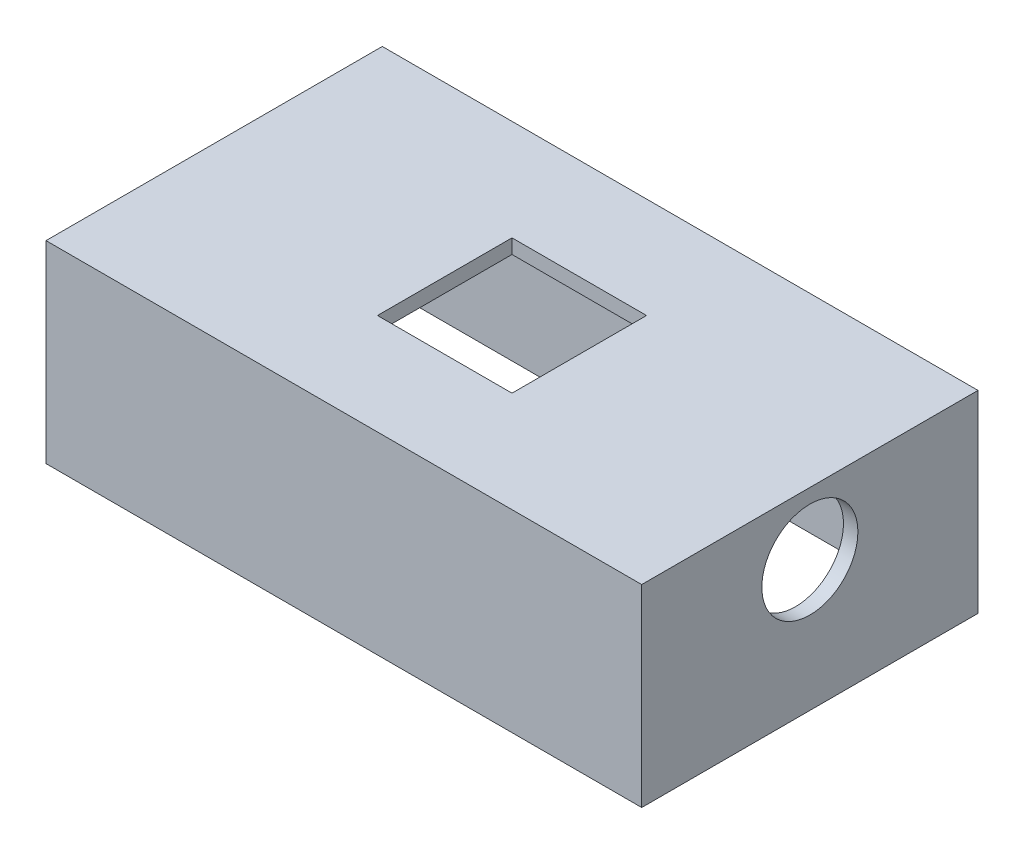
from build123d import *

# Parameters (mm, degrees)
SKETCH_1_W          = 62
SKETCH_1_H          = 35
EXTRUDE_1_DEPTH     = 1.5
SKETCH_2_W          = 62
SKETCH_2_H          = 35
EXTRUDE_2_DEPTH     = 16.1
SKETCH_3_W          = 59
SKETCH_3_H          = 32
CUT_EXTRUDE_1_DEPTH = 41
SKETCH_4_W          = 62
SKETCH_4_H          = 35
SKETCH_4_W_2        = 59
SKETCH_4_H_2        = 32
EXTRUDE_3_DEPTH     = 1
SKETCH_5_W          = 62
SKETCH_5_H          = 35
EXTRUDE_4_DEPTH     = 1.5
SKETCH_8_R          = 5
CUT_EXTRUDE_3_DEPTH = 1.5
CUT_EXTRUDE_4_REACH = 22.1
SKETCH_10_W         = 14
SKETCH_10_H         = 14


with BuildPart() as part:
    # 草图1 → 凸台-拉伸1 (new body)
    with BuildSketch(Plane(origin=(0, 0, 0), x_dir=(1, 0, 0), z_dir=(0, 1, 0))):
        with Locations((2.996831225, 4.751847291)):
            Rectangle(SKETCH_1_W, SKETCH_1_H)
    extrude(amount=EXTRUDE_1_DEPTH)

    # 草图2 → 凸台-拉伸2 (add)
    with BuildSketch(Plane.XZ):
        with Locations((2.996831225, -4.751847291)):
            Rectangle(SKETCH_2_W, SKETCH_2_H)
    extrude(amount=EXTRUDE_2_DEPTH)

    # 草图3 → 切除-拉伸1 (cut)
    with BuildSketch(Plane.XZ.offset(16.1)):
        with Locations((2.996831225, -4.751847291)):
            Rectangle(SKETCH_3_W, SKETCH_3_H)
    extrude(amount=-CUT_EXTRUDE_1_DEPTH, mode=Mode.SUBTRACT)

    # 草图4 → 凸台-拉伸3 (add)
    with BuildSketch(Plane(origin=(0, 1.5, 0), x_dir=(1, 0, 0), z_dir=(0, 1, 0))):
        with Locations((2.996831225, 4.751847291)):
            Rectangle(SKETCH_4_W, SKETCH_4_H)
        with Locations((2.996831225, 4.751847291)):
            Rectangle(SKETCH_4_W_2, SKETCH_4_H_2, mode=Mode.SUBTRACT)
    extrude(amount=EXTRUDE_3_DEPTH)

    # 草图5 → 凸台-拉伸4 (add)
    with BuildSketch(Plane(origin=(0, 2.5, 0), x_dir=(1, 0, 0), z_dir=(0, 1, 0))):
        with Locations((2.996831225, 4.751847291)):
            Rectangle(SKETCH_5_W, SKETCH_5_H)
    extrude(amount=EXTRUDE_4_DEPTH)

    # 草图8 → 切除-拉伸3 (cut)
    with BuildSketch(Plane(origin=(33.996831225, 0, 0), x_dir=(0, 0, -1), z_dir=(1, 0, 0))):
        with Locations((4.751847291, -2.5)):
            Circle(SKETCH_8_R)
    extrude(amount=-CUT_EXTRUDE_3_DEPTH, mode=Mode.SUBTRACT)

    # 草图10 → 切除-拉伸4 (cut, up to next)
    with BuildSketch(Plane(origin=(0, 4, 0), x_dir=(1, 0, 0), z_dir=(0, 1, 0)), mode=Mode.PRIVATE) as cut_extrude_4_sk1:
        with Locations((2.996831225, 4.751847291)):
            Rectangle(SKETCH_10_W, SKETCH_10_H)
    cut_extrude_4_tool1 = extrude(cut_extrude_4_sk1.sketch, amount=-CUT_EXTRUDE_4_REACH, mode=Mode.PRIVATE) & part.part
    add(cut_extrude_4_tool1.solids().sort_by_distance((2.996831, 4, -4.751847))[0], mode=Mode.SUBTRACT)


solid = part.part
